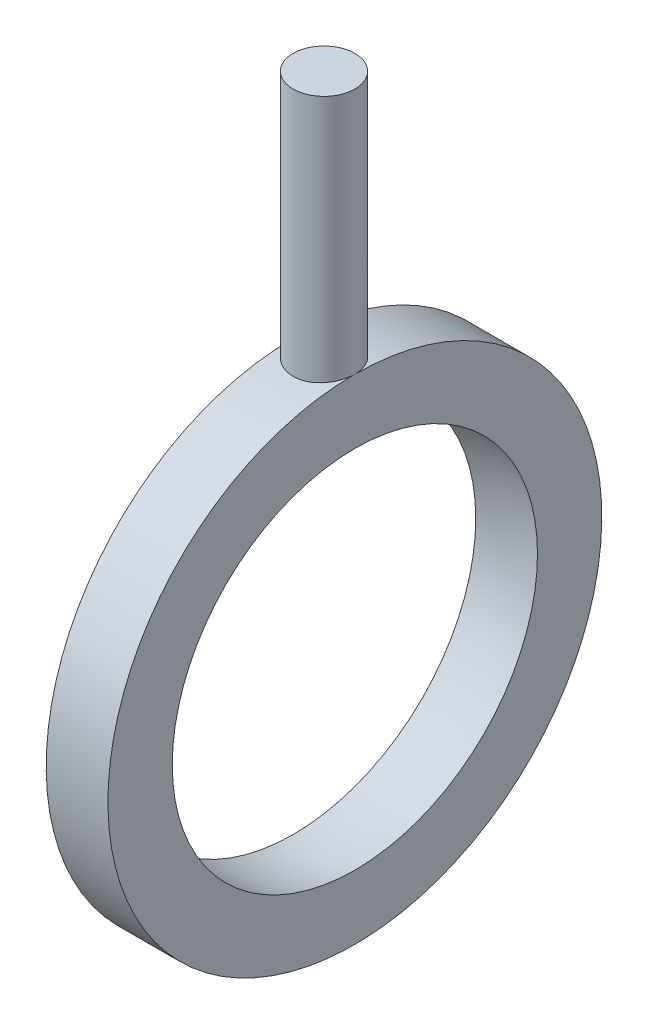
from build123d import *

# Parameters (mm, degrees)
BOSS_EXTRUDE2_REACH = 62
SKETCH3_R           = 2.5


with BuildPart() as part:
    # Sketch1 → Revolve1 (revolve)
    with BuildSketch(Plane.XY):
        with BuildLine():
            Line((-2.5, 20), (2.5, 20))
            Line((2.5, 20), (2.5, 14.790199458))
            ThreePointArc((2.5, 14.790199458), (0, 15), (-2.5, 14.790199458))
            Line((-2.5, 14.790199458), (-2.5, 20))
        make_face()
    revolve(axis=Axis((0, 0, 0), (1, 0, 0)))

    # Sketch3 → Boss-Extrude2 (add, up to next)
    with BuildSketch(Plane(origin=(0, 40, 0), x_dir=(1, 0, 0), z_dir=(0, 1, 0)), mode=Mode.PRIVATE) as boss_extrude2_sk1:
        Circle(SKETCH3_R)
    boss_extrude2_tool1 = extrude(boss_extrude2_sk1.sketch, amount=-BOSS_EXTRUDE2_REACH, mode=Mode.PRIVATE) - part.part
    add(boss_extrude2_tool1.solids().sort_by_distance((0, 40, 0))[0])


solid = part.part
